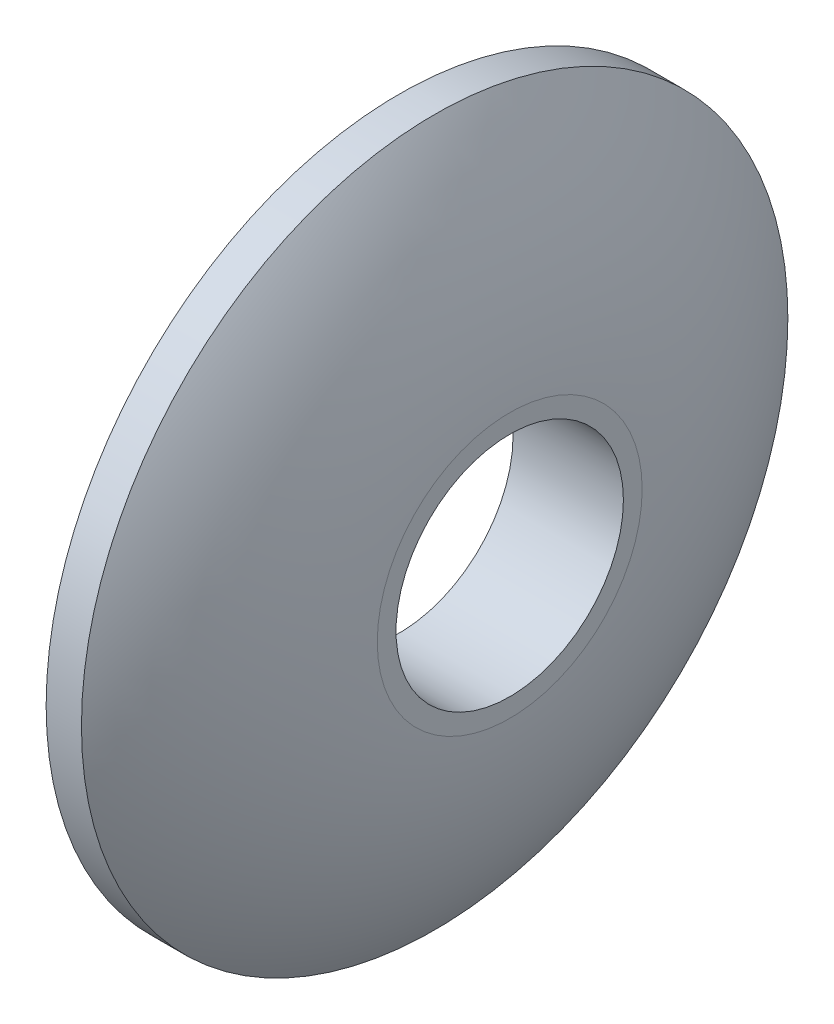
from build123d import *

# Parameters (mm, degrees)
SKETCH5_R          = 2.575
CUT_EXTRUDE3_DEPTH = 3.5


with BuildPart() as part:
    # Sketch1 → Revolve1 (revolve)
    with BuildSketch(Plane.XY):
        with BuildLine():
            Line((0, 0), (0, 8))
            Line((0, 8), (0.8, 8))
            ThreePointArc((0.8, 8), (1.98603193, 5.614250856), (2.5, 3))
            Line((2.5, 3), (2.5, 0))
            Line((2.5, 0), (0, 0))
        make_face()
    revolve(axis=Axis((-13.276595745, 0, 0), (1, 0, 0)))

    # Sketch5 → Cut-Extrude3 (cut, through all)
    with BuildSketch(Plane(origin=(2.5, 0, 0), x_dir=(0, 0, -1), z_dir=(1, 0, 0))):
        Circle(SKETCH5_R)
    extrude(amount=-CUT_EXTRUDE3_DEPTH, mode=Mode.SUBTRACT)


solid = part.part
